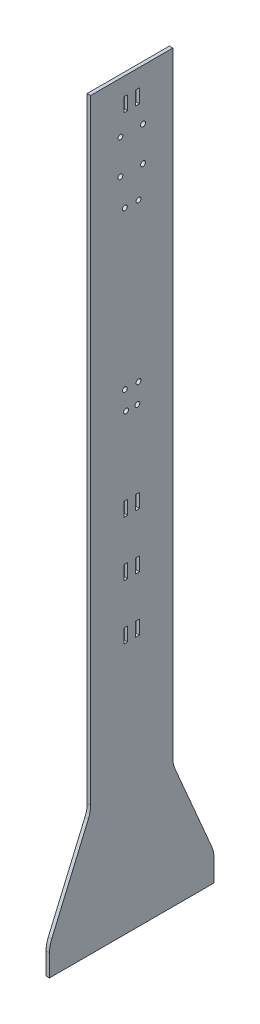
from build123d import *

# Parameters (mm, degrees)
SKETCH1_W                     = 76.2
SKETCH1_H                     = 914.4
BOSS_EXTRUDE1_DEPTH           = 3.175
SKETCH2_W                     = 3.556
SKETCH2_H                     = 12.954
CUT_EXTRUDE1_DEPTH            = 4.175
LPATTERN1_COUNT               = 2
LPATTERN1_PITCH               = 50.8
LPATTERN1_COPY_1_SKETCH_W     = 3.556
LPATTERN1_COPY_1_SKETCH_H     = 12.954
LPATTERN1_COPY_1_DEPTH        = 4.175
LPATTERN1_COL_COUNT           = 2
LPATTERN1_COL_PITCH           = 50.8
LPATTERN1_COL_COPY_1_SKETCH_W = 3.556
LPATTERN1_COL_COPY_1_SKETCH_H = 12.954
LPATTERN1_COL_COPY_1_DEPTH    = 4.175
SKETCH3_W                     = 3.556
SKETCH3_H                     = 12.954
CUT_EXTRUDE2_DEPTH            = 4.175
F_8_CLEARANCE_HOLE1_D         = 4.4958
CUT_EXTRUDE3_DEPTH            = 1
CUT_EXTRUDE3_DEPTH_BACK       = 4.175
BOSS_EXTRUDE2_DEPTH           = 3.175
BOSS_EXTRUDE3_DEPTH           = 3.175
FILLET1_R                     = 25.4
F_8_CLEARANCE_HOLE2_D         = 4.4958


with BuildPart() as part:
    # Sketch1 → Boss-Extrude1 (new body)
    with BuildSketch(Plane(origin=(0, 0, 0), x_dir=(0, 0, -1), z_dir=(1, 0, 0))):
        Rectangle(SKETCH1_W, SKETCH1_H)
    extrude(amount=BOSS_EXTRUDE1_DEPTH)

    # Sketch2 → Cut-Extrude1 (cut, through all)
    with BuildSketch(Plane(origin=(3.175, 0, 0), x_dir=(0, 0, -1), z_dir=(1, 0, 0))):
        with Locations((5.499997, -211.0105)):
            Rectangle(SKETCH2_W, SKETCH2_H)
    cut_extrude1 = extrude(amount=-CUT_EXTRUDE1_DEPTH, mode=Mode.SUBTRACT)

    # Mirror1: Cut-Extrude1 across plane
    add(cut_extrude1.mirror(Plane.XY), mode=Mode.SUBTRACT)

    # LPattern1: Cut-Extrude1 ×2
    with Locations(*[(0, i * LPATTERN1_PITCH, 0) for i in range(1, LPATTERN1_COUNT)]):
        add(cut_extrude1, mode=Mode.SUBTRACT)

    # LPattern1 copy 1 sketch → LPattern1 copy 1 (cut, through all)
    with BuildSketch(Plane(origin=(3.175, 50.8, 0), x_dir=(0, 0, 1), z_dir=(1, 0, 0))):
        with Locations((5.499997, 211.0105)):
            Rectangle(LPATTERN1_COPY_1_SKETCH_W, LPATTERN1_COPY_1_SKETCH_H)
    extrude(amount=-LPATTERN1_COPY_1_DEPTH, mode=Mode.SUBTRACT)

    # LPattern1 col: Cut-Extrude1 ×2
    with Locations(*[(0, -i * LPATTERN1_COL_PITCH, 0) for i in range(1, LPATTERN1_COL_COUNT)]):
        add(cut_extrude1, mode=Mode.SUBTRACT)

    # LPattern1 col copy 1 sketch → LPattern1 col copy 1 (cut, through all)
    with BuildSketch(Plane(origin=(3.175, -50.8, 0), x_dir=(0, 0, 1), z_dir=(1, 0, 0))):
        with Locations((5.499997, 211.0105)):
            Rectangle(LPATTERN1_COL_COPY_1_SKETCH_W, LPATTERN1_COL_COPY_1_SKETCH_H)
    extrude(amount=-LPATTERN1_COL_COPY_1_DEPTH, mode=Mode.SUBTRACT)

    # Sketch3 → Cut-Extrude2 (cut, through all)
    with BuildSketch(Plane(origin=(3.175, 0, 0), x_dir=(0, 0, -1), z_dir=(1, 0, 0))):
        with Locations((5.499997, 164.431090402)):
            Rectangle(SKETCH3_W, SKETCH3_H)
        with Locations((-5.499997, 164.431090402)):
            Rectangle(SKETCH3_W, SKETCH3_H)
    extrude(amount=-CUT_EXTRUDE2_DEPTH, mode=Mode.SUBTRACT)

    # #8 Clearance Hole1 (through all)
    with Locations(Plane(origin=(3.175, 0, 0), x_dir=(0, 0, -1), z_dir=(1, 0, 0))):
        with Locations((6.35, -64.523692353), (-6.35, -64.523692353), (6.35, 81.271985669), (-6.35, 81.271985669), (5.25, -82.226052879), (-5.25, -82.226052879)):
            Hole(F_8_CLEARANCE_HOLE1_D / 2)

    # Sketch6 → Cut-Extrude3 (cut, two sides)
    with BuildSketch(Plane(origin=(3.175, 0, 0), x_dir=(0, 0, -1), z_dir=(1, 0, 0))) as cut_extrude3_sk:
        Polygon((-1346.127604676, 187.325), (-38.1, 187.325), (38.1, 187.325), (1346.127604676, 187.325), (1346.127604676, 2803.380209351), (-1346.127604676, 2803.380209351), align=None)
    extrude(amount=CUT_EXTRUDE3_DEPTH, mode=Mode.SUBTRACT)
    extrude(cut_extrude3_sk.sketch, amount=-CUT_EXTRUDE3_DEPTH_BACK, mode=Mode.SUBTRACT)

    # Sketch7 → Boss-Extrude2 (add)
    with BuildSketch(Plane(origin=(3.175, 0, 0), x_dir=(0, 0, -1), z_dir=(1, 0, 0))):
        Polygon((-38.1, -457.2), (-38.1, -501.65), (0, -501.65), (38.1, -501.65), (38.1, -457.2), align=None)
    extrude(amount=-BOSS_EXTRUDE2_DEPTH)

    # Sketch8 → Boss-Extrude3 (add)
    with BuildSketch(Plane(origin=(3.175, 0, 0), x_dir=(0, 0, -1), z_dir=(1, 0, 0))):
        Polygon((-38.1, -387.35), (-76.2, -476.25), (-76.2, -501.65), (76.2, -501.65), (76.2, -476.25), (38.1, -387.35), align=None)
    extrude(amount=-BOSS_EXTRUDE3_DEPTH)

    # Fillet1
    fillet1_edges = [part.edges().sort_by_distance(p)[0] for p in [
        (1.5875, -387.35, 38.1),
        (1.5875, -387.35, -38.1),
        (1.5875, -476.25, -76.2),
        (1.5875, -476.25, 76.2),
    ]]
    fillet(fillet1_edges, radius=FILLET1_R)

    # #8 Clearance Hole2 (through all)
    with Locations(Plane.ZY):
        with Locations((10.4775, 108.326326852), (-10.4775, 108.326326852), (-10.4775, 140.076326852), (10.4775, 140.076326852)):
            Hole(F_8_CLEARANCE_HOLE2_D / 2)


solid = part.part
